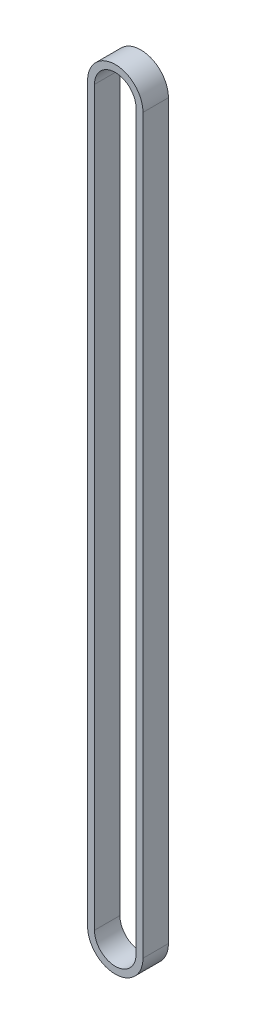
from build123d import *

# Parameters (mm, degrees)
EXTRUDE_1_DEPTH = 7.4


with BuildPart() as part:
    # Эскиз1 → Бобышка-Вытянуть1 (new body)
    with BuildSketch(Plane.XY):
        with BuildLine():
            Line((-8.05, 213), (-8.05, 0))
            ThreePointArc((-8.05, 0), (0, -8.05), (8.05, 0))
            Line((8.05, 0), (8.05, 213))
            ThreePointArc((8.05, 213), (0, 221.05), (-8.05, 213))
        make_face()
        with BuildLine():
            Line((-6.05, 0), (-6.05, 213))
            ThreePointArc((-6.05, 213), (0, 219.05), (6.05, 213))
            Line((6.05, 213), (6.05, 0))
            ThreePointArc((6.05, 0), (0, -6.05), (-6.05, 0))
        make_face(mode=Mode.SUBTRACT)
    extrude(amount=EXTRUDE_1_DEPTH)


solid = part.part
